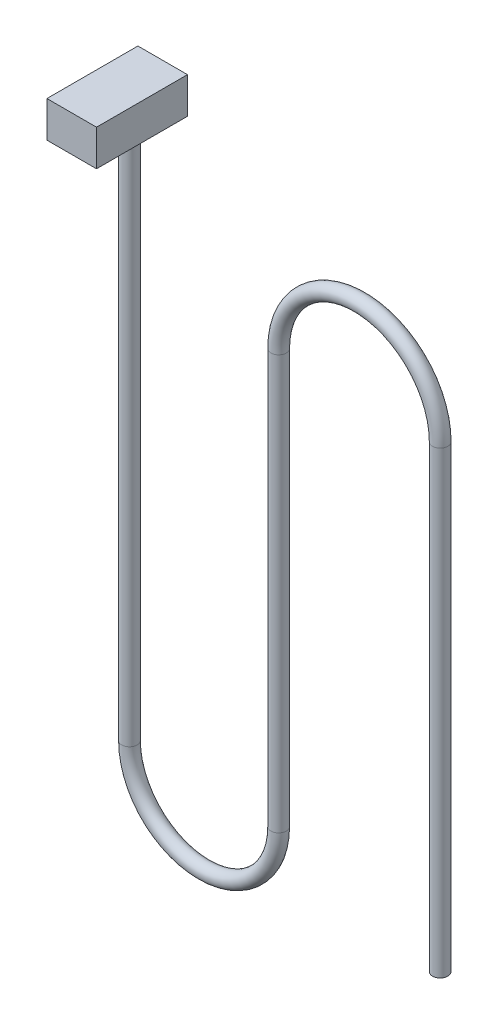
from build123d import *

# Parameters (mm, degrees)
SKETCH1_W           = 8.177357898
SKETCH1_H           = 5.946767651
BOSS_EXTRUDE1_DEPTH = 15
SKETCH2_R           = 1.27


with BuildPart() as part:
    # Sketch1 → Boss-Extrude1 (new body)
    with BuildSketch(Plane.XY):
        with Locations((-51.319507827, 71.357432061)):
            Rectangle(SKETCH1_W, SKETCH1_H)
    extrude(amount=-BOSS_EXTRUDE1_DEPTH)

    # Sweep1: sweep along a path in Sketch3
    with BuildLine(Plane.XY.offset(-9.522776034)) as sweep1_path:
        Line((-51.319507827, 68.384048236), (-51.319507827, -20.048994445))
        ThreePointArc((-51.319507827, -20.048994445), (-39.023171295, -32.345330977), (-26.726834763, -20.048994445))
        Line((-26.726834763, -20.048994445), (-26.726834763, 48.210546245))
        ThreePointArc((-26.726834763, 48.210546245), (-13.409077555, 61.528303453), (-0.091320347, 48.210546245))
        Line((-0.091320347, 48.210546245), (-0.091320347, -27.444646548))
    # Sketch2 → Sweep1 (sweep)
    with BuildSketch(Plane.XZ.offset(-68.384048236)):
        with Locations((-51.319507827, -9.522776034)):
            Circle(SKETCH2_R)
    sweep(path=sweep1_path.line)


solid = part.part
